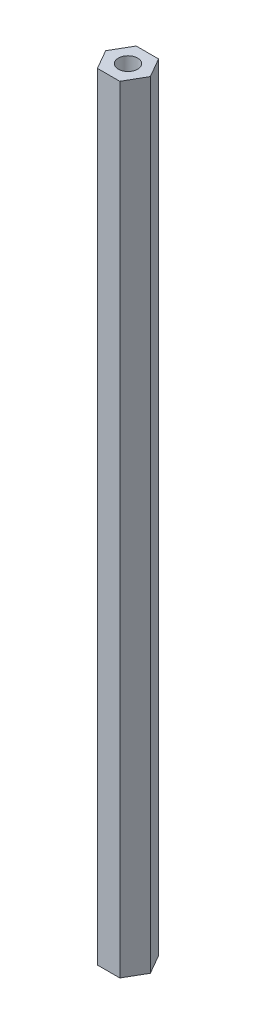
from build123d import *

# Parameters (mm, degrees)
BOSS_EXTRUDE1_DEPTH = 50.1015


with BuildPart() as part:
    # Sketch1 → Boss-Extrude1 (new, symmetric)
    with BuildSketch(Plane(origin=(0, 0, 0), x_dir=(1, 0, 0), z_dir=(0, 1, 0))):
        Polygon((2.886751346, 0), (1.443375673, 2.5), (-1.443375673, 2.5), (-2.886751346, 0), (-1.443375673, -2.5), (1.443375673, -2.5), align=None)
    extrude(amount=BOSS_EXTRUDE1_DEPTH, both=True)

    # Sketch3 → M3x0.5 Tapped Hole1 (revolve, cut)
    with BuildSketch(Plane(origin=(0, 50.1015, 0), x_dir=(0, 0, 1), z_dir=(1, 0, 0))):
        Polygon((0, 0), (0, 10.276075774), (1.25, 9.525), (1.25, 0), align=None)
    m3x0_5_tapped_hole1 = revolve(axis=Axis((0, 56.4515, 0), (0, -1, 0)), mode=Mode.SUBTRACT)

    # Mirror1: M3x0.5 Tapped Hole1 across plane
    add(m3x0_5_tapped_hole1.mirror(Plane.ZX), mode=Mode.SUBTRACT)


solid = part.part
